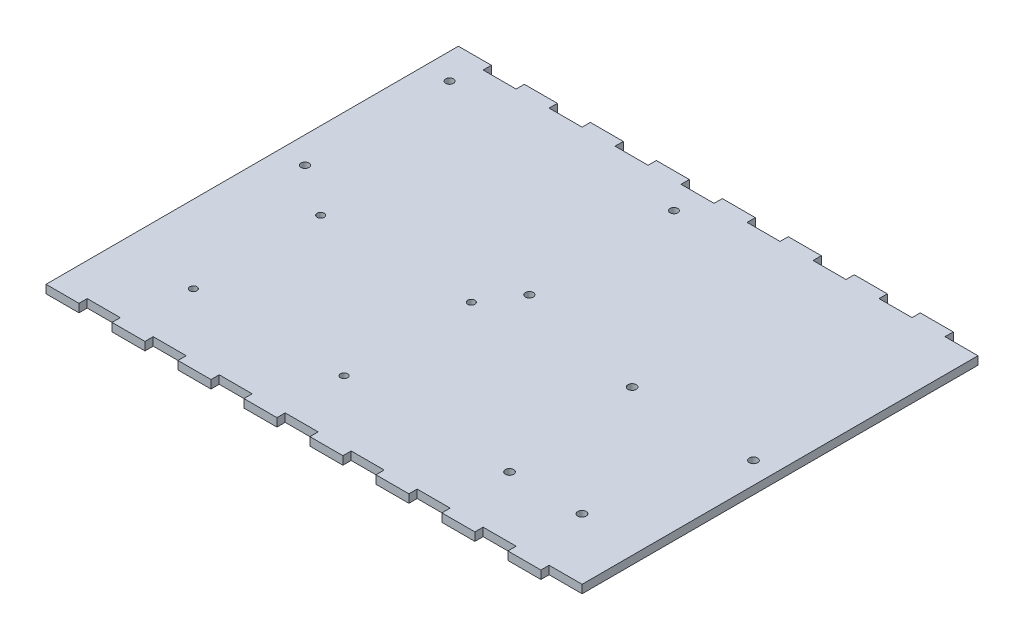
from build123d import *

# Parameters (mm, degrees)
SKETCH1_W              = 203.2
SKETCH1_H              = 152.4
BOSS_EXTRUDE1_DEPTH    = 3.175
SKETCH2_W              = 12.7
SKETCH2_H              = 3.175
BOSS_EXTRUDE2_DEPTH    = 3.175
BOSS_EXTRUDE2_2_DEPTH  = 3.175
BOSS_EXTRUDE2_3_DEPTH  = 3.175
BOSS_EXTRUDE2_4_DEPTH  = 3.175
BOSS_EXTRUDE2_5_DEPTH  = 3.175
BOSS_EXTRUDE2_6_DEPTH  = 3.175
BOSS_EXTRUDE2_7_DEPTH  = 3.175
BOSS_EXTRUDE2_8_DEPTH  = 3.175
BOSS_EXTRUDE2_9_DEPTH  = 3.175
BOSS_EXTRUDE2_10_DEPTH = 3.175
BOSS_EXTRUDE2_11_DEPTH = 3.175
BOSS_EXTRUDE2_12_DEPTH = 3.175
BOSS_EXTRUDE2_13_DEPTH = 3.175
BOSS_EXTRUDE2_14_DEPTH = 3.175
BOSS_EXTRUDE2_15_DEPTH = 3.175
BOSS_EXTRUDE2_16_DEPTH = 3.175
SKETCH4_R              = 1.375
RASPI_DEPTH            = 4.175
SKETCH5_R              = 1.6
ARDUINO_DEPTH          = 4.175
SKETCH10_R             = 1.535
SKETCH10_R_2           = 1.5
PERFBOARD_DEPTH        = 1
PERFBOARD_DEPTH_BACK   = 4.175


with BuildPart() as part:
    # Sketch1 → Boss-Extrude1 (new body)
    with BuildSketch(Plane(origin=(0, 0, 0), x_dir=(1, 0, 0), z_dir=(0, 1, 0))):
        with Locations((101.6, 76.2)):
            Rectangle(SKETCH1_W, SKETCH1_H)
    extrude(amount=BOSS_EXTRUDE1_DEPTH)

    # Sketch4 → Raspi (cut, through all)
    with BuildSketch(Plane(origin=(163.318517222, 3.175, 18.128898402), x_dir=(-1, 0, 0), z_dir=(0, 1, 0))):
        with Locations((75.468517222, -41.828898402)):
            Circle(SKETCH4_R)
        with Locations((75.468517222, -90.828898402)):
            Circle(SKETCH4_R)
        with Locations((133.468517222, -90.828898402)):
            Circle(SKETCH4_R)
        with Locations((133.468517222, -41.828898402)):
            Circle(SKETCH4_R)
    extrude(amount=-RASPI_DEPTH, mode=Mode.SUBTRACT)

    # Sketch5 → Arduino (cut, through all)
    with BuildSketch(Plane(origin=(-58.332709996, 3.175, -175.865858612), x_dir=(0, 0, 1), z_dir=(0, 1, 0))):
        with Locations((100.475405858, 205.398928035)):
            Circle(SKETCH5_R)
        with Locations((101.575405858, 253.198928035)):
            Circle(SKETCH5_R)
        with Locations((152.375405858, 210.098928035)):
            Circle(SKETCH5_R)
        with Locations((152.375405858, 237.998928035)):
            Circle(SKETCH5_R)
    extrude(amount=-ARDUINO_DEPTH, mode=Mode.SUBTRACT)

    # Sketch10 → Perfboard (cut, two sides)
    with BuildSketch(Plane(origin=(154.738240667, 3.175, -89.784200023), x_dir=(0, 0, -1), z_dir=(0, 1, 0))) as perfboard_sk:
        with Locations((-3.423776116, 144.568240667)):
            Circle(SKETCH10_R)
        with Locations((52.455799977, 144.785900219)):
            Circle(SKETCH10_R_2)
        with Locations((-3.423776116, 58.208240667)):
            Circle(SKETCH10_R)
        with Locations((52.455799977, 58.425900219)):
            Circle(SKETCH10_R_2)
    extrude(amount=PERFBOARD_DEPTH, mode=Mode.SUBTRACT)
    extrude(perfboard_sk.sketch, amount=-PERFBOARD_DEPTH_BACK, mode=Mode.SUBTRACT)


with BuildPart() as body_2:
    # Sketch2 → Boss-Extrude2 (new body)
    with BuildSketch(Plane(origin=(0, 3.175, 0), x_dir=(1, 0, 0), z_dir=(0, 1, 0))):
        with Locations((31.75, -1.5875)):
            Rectangle(SKETCH2_W, SKETCH2_H)
    extrude(amount=-BOSS_EXTRUDE2_DEPTH)


with BuildPart() as body_3:
    # Sketch2 → Boss-Extrude2 2 (new body)
    with BuildSketch(Plane(origin=(0, 3.175, 0), x_dir=(1, 0, 0), z_dir=(0, 1, 0))):
        with Locations((6.35, -1.5875)):
            Rectangle(SKETCH2_W, SKETCH2_H)
    extrude(amount=-BOSS_EXTRUDE2_2_DEPTH)


with BuildPart() as body_4:
    # Sketch2 → Boss-Extrude2 3 (new body)
    with BuildSketch(Plane(origin=(0, 3.175, 0), x_dir=(1, 0, 0), z_dir=(0, 1, 0))):
        with Locations((57.15, -1.5875)):
            Rectangle(SKETCH2_W, SKETCH2_H)
    extrude(amount=-BOSS_EXTRUDE2_3_DEPTH)


with BuildPart() as body_5:
    # Sketch2 → Boss-Extrude2 4 (new body)
    with BuildSketch(Plane(origin=(0, 3.175, 0), x_dir=(1, 0, 0), z_dir=(0, 1, 0))):
        with Locations((82.55, -1.5875)):
            Rectangle(SKETCH2_W, SKETCH2_H)
    extrude(amount=-BOSS_EXTRUDE2_4_DEPTH)


with BuildPart() as body_6:
    # Sketch2 → Boss-Extrude2 5 (new body)
    with BuildSketch(Plane(origin=(0, 3.175, 0), x_dir=(1, 0, 0), z_dir=(0, 1, 0))):
        with Locations((107.95, -1.5875)):
            Rectangle(SKETCH2_W, SKETCH2_H)
    extrude(amount=-BOSS_EXTRUDE2_5_DEPTH)


with BuildPart() as body_7:
    # Sketch2 → Boss-Extrude2 6 (new body)
    with BuildSketch(Plane(origin=(0, 3.175, 0), x_dir=(1, 0, 0), z_dir=(0, 1, 0))):
        with Locations((133.35, -1.5875)):
            Rectangle(SKETCH2_W, SKETCH2_H)
    extrude(amount=-BOSS_EXTRUDE2_6_DEPTH)


with BuildPart() as body_8:
    # Sketch2 → Boss-Extrude2 7 (new body)
    with BuildSketch(Plane(origin=(0, 3.175, 0), x_dir=(1, 0, 0), z_dir=(0, 1, 0))):
        with Locations((158.75, -1.5875)):
            Rectangle(SKETCH2_W, SKETCH2_H)
    extrude(amount=-BOSS_EXTRUDE2_7_DEPTH)


with BuildPart() as body_9:
    # Sketch2 → Boss-Extrude2 8 (new body)
    with BuildSketch(Plane(origin=(0, 3.175, 0), x_dir=(1, 0, 0), z_dir=(0, 1, 0))):
        with Locations((184.15, -1.5875)):
            Rectangle(SKETCH2_W, SKETCH2_H)
    extrude(amount=-BOSS_EXTRUDE2_8_DEPTH)


with BuildPart() as body_10:
    # Sketch2 → Boss-Extrude2 9 (new body)
    with BuildSketch(Plane(origin=(0, 3.175, 0), x_dir=(1, 0, 0), z_dir=(0, 1, 0))):
        with Locations((184.15, 153.9875)):
            Rectangle(SKETCH2_W, SKETCH2_H)
    extrude(amount=-BOSS_EXTRUDE2_9_DEPTH)


with BuildPart() as body_11:
    # Sketch2 → Boss-Extrude2 10 (new body)
    with BuildSketch(Plane(origin=(0, 3.175, 0), x_dir=(1, 0, 0), z_dir=(0, 1, 0))):
        with Locations((158.75, 153.9875)):
            Rectangle(SKETCH2_W, SKETCH2_H)
    extrude(amount=-BOSS_EXTRUDE2_10_DEPTH)


with BuildPart() as body_12:
    # Sketch2 → Boss-Extrude2 11 (new body)
    with BuildSketch(Plane(origin=(0, 3.175, 0), x_dir=(1, 0, 0), z_dir=(0, 1, 0))):
        with Locations((133.35, 153.9875)):
            Rectangle(SKETCH2_W, SKETCH2_H)
    extrude(amount=-BOSS_EXTRUDE2_11_DEPTH)


with BuildPart() as body_13:
    # Sketch2 → Boss-Extrude2 12 (new body)
    with BuildSketch(Plane(origin=(0, 3.175, 0), x_dir=(1, 0, 0), z_dir=(0, 1, 0))):
        with Locations((107.95, 153.9875)):
            Rectangle(SKETCH2_W, SKETCH2_H)
    extrude(amount=-BOSS_EXTRUDE2_12_DEPTH)


with BuildPart() as body_14:
    # Sketch2 → Boss-Extrude2 13 (new body)
    with BuildSketch(Plane(origin=(0, 3.175, 0), x_dir=(1, 0, 0), z_dir=(0, 1, 0))):
        with Locations((82.55, 153.9875)):
            Rectangle(SKETCH2_W, SKETCH2_H)
    extrude(amount=-BOSS_EXTRUDE2_13_DEPTH)


with BuildPart() as body_15:
    # Sketch2 → Boss-Extrude2 14 (new body)
    with BuildSketch(Plane(origin=(0, 3.175, 0), x_dir=(1, 0, 0), z_dir=(0, 1, 0))):
        with Locations((57.15, 153.9875)):
            Rectangle(SKETCH2_W, SKETCH2_H)
    extrude(amount=-BOSS_EXTRUDE2_14_DEPTH)


with BuildPart() as body_16:
    # Sketch2 → Boss-Extrude2 15 (new body)
    with BuildSketch(Plane(origin=(0, 3.175, 0), x_dir=(1, 0, 0), z_dir=(0, 1, 0))):
        with Locations((31.75, 153.9875)):
            Rectangle(SKETCH2_W, SKETCH2_H)
    extrude(amount=-BOSS_EXTRUDE2_15_DEPTH)


with BuildPart() as body_17:
    # Sketch2 → Boss-Extrude2 16 (new body)
    with BuildSketch(Plane(origin=(0, 3.175, 0), x_dir=(1, 0, 0), z_dir=(0, 1, 0))):
        with Locations((6.35, 153.9875)):
            Rectangle(SKETCH2_W, SKETCH2_H)
    extrude(amount=-BOSS_EXTRUDE2_16_DEPTH)


with BuildPart() as body_3_1:
    add(body_3.part)

    # Combine1: union body 4, body 6, body 8, body 10, body 12, body 14, body 16, body 17, part, body 2, body 5, body 7, body 9, body 11, body 13, body 15
    add(body_4.part)
    add(body_6.part)
    add(body_8.part)
    add(body_10.part)
    add(body_12.part)
    add(body_14.part)
    add(body_16.part)
    add(body_17.part)
    add(part.part)
    add(body_2.part)
    add(body_5.part)
    add(body_7.part)
    add(body_9.part)
    add(body_11.part)
    add(body_13.part)
    add(body_15.part)


solid = body_3_1.part
